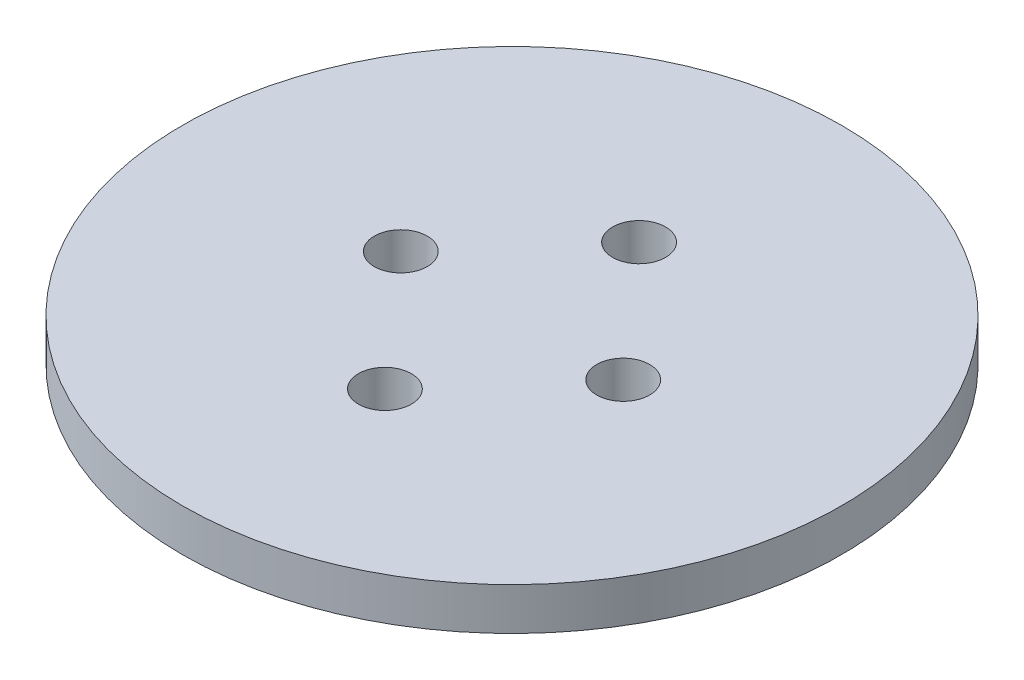
from build123d import *

# Parameters (mm, degrees)
SKETCH1_R            = 49.403
BOSS_EXTRUDE1_DEPTH  = 6.35
THREADED_ROD_HOLES_D = 7.9375
U_BOLT_HOLES_D       = 7.9375


with BuildPart() as part:
    # Sketch1 → Boss-Extrude1 (new body)
    with BuildSketch(Plane(origin=(0, 0, 0), x_dir=(1, 0, 0), z_dir=(0, 1, 0))):
        Circle(SKETCH1_R)
    extrude(amount=BOSS_EXTRUDE1_DEPTH)

    # Threaded Rod Holes (through all)
    with Locations(Plane(origin=(0, 6.35, 0), x_dir=(1, 0, 0), z_dir=(0, 1, 0))):
        with Locations((0, 19.05), (0, -19.05)):
            Hole(THREADED_ROD_HOLES_D / 2)

    # U-Bolt Holes (through all)
    with Locations(Plane(origin=(0, 6.35, 0), x_dir=(1, 0, 0), z_dir=(0, 1, 0))):
        with Locations((-16.66875, 0), (16.66875, 0)):
            Hole(U_BOLT_HOLES_D / 2)


solid = part.part
